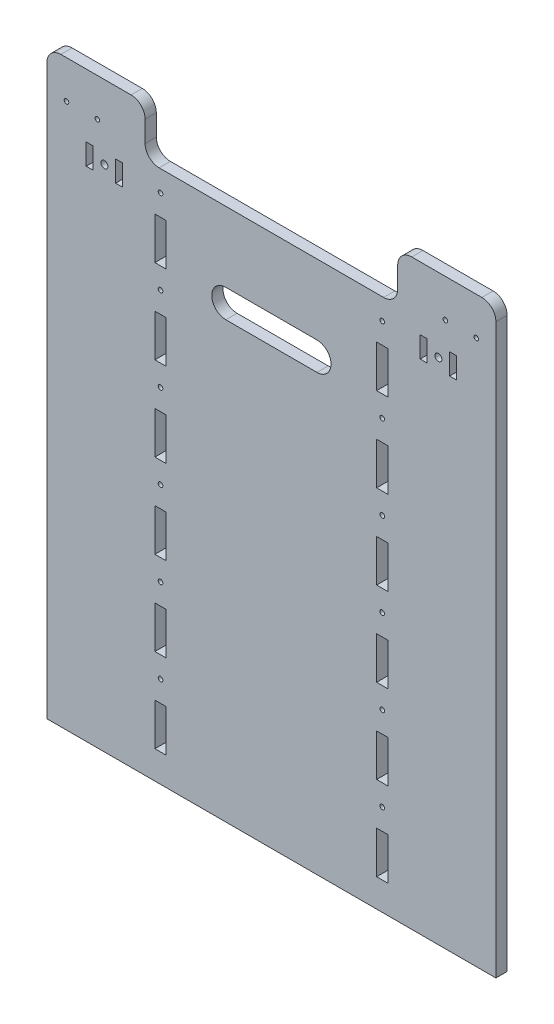
from build123d import *

# Parameters (mm, degrees)
SKETCH1_R           = 1.625
SKETCH1_R_2         = 2.5
SKETCH1_R_3         = 1.65
SKETCH1_W           = 8
SKETCH1_H           = 30
SKETCH1_W_2         = 5
SKETCH1_H_2         = 15
BOSS_EXTRUDE1_DEPTH = 8
FILLET1_R           = 10
CUT_EXTRUDE1_DEPTH  = 9


with BuildPart() as part:
    # Sketch1 → Boss-Extrude1 (new body)
    with BuildSketch(Plane.XY):
        Polygon((70, 380), (250, 380), (250, 415), (320, 415), (320, 0), (0, 0), (0, 415), (70, 415), align=None)
        with Locations((14, 388)):
            Circle(SKETCH1_R, mode=Mode.SUBTRACT)
        with Locations((36, 388)):
            Circle(SKETCH1_R, mode=Mode.SUBTRACT)
        with Locations((41, 362.5)):
            Circle(SKETCH1_R_2, mode=Mode.SUBTRACT)
        with Locations((279, 362.5)):
            Circle(SKETCH1_R_2, mode=Mode.SUBTRACT)
        with Locations((284, 388)):
            Circle(SKETCH1_R, mode=Mode.SUBTRACT)
        with Locations((306, 388)):
            Circle(SKETCH1_R, mode=Mode.SUBTRACT)
        with Locations((239, 365)):
            Circle(SKETCH1_R_3, mode=Mode.SUBTRACT)
        with Locations((81, 365)):
            Circle(SKETCH1_R_3, mode=Mode.SUBTRACT)
        with Locations((239, 305)):
            Circle(SKETCH1_R_3, mode=Mode.SUBTRACT)
        with Locations((81, 305)):
            Circle(SKETCH1_R_3, mode=Mode.SUBTRACT)
        with Locations((239, 245)):
            Circle(SKETCH1_R_3, mode=Mode.SUBTRACT)
        with Locations((81, 245)):
            Circle(SKETCH1_R_3, mode=Mode.SUBTRACT)
        with Locations((239, 185)):
            Circle(SKETCH1_R_3, mode=Mode.SUBTRACT)
        with Locations((81, 185)):
            Circle(SKETCH1_R_3, mode=Mode.SUBTRACT)
        with Locations((239, 125)):
            Circle(SKETCH1_R_3, mode=Mode.SUBTRACT)
        with Locations((81, 125)):
            Circle(SKETCH1_R_3, mode=Mode.SUBTRACT)
        with Locations((239, 65)):
            Circle(SKETCH1_R_3, mode=Mode.SUBTRACT)
        with Locations((81, 65)):
            Circle(SKETCH1_R_3, mode=Mode.SUBTRACT)
        with Locations((81, 35)):
            Rectangle(SKETCH1_W, SKETCH1_H, mode=Mode.SUBTRACT)
        with Locations((30.5, 362.5)):
            Rectangle(SKETCH1_W_2, SKETCH1_H_2, mode=Mode.SUBTRACT)
        with Locations((51.5, 362.5)):
            Rectangle(SKETCH1_W_2, SKETCH1_H_2, mode=Mode.SUBTRACT)
        with Locations((268.5, 362.5)):
            Rectangle(SKETCH1_W_2, SKETCH1_H_2, mode=Mode.SUBTRACT)
        with Locations((289.5, 362.5)):
            Rectangle(SKETCH1_W_2, SKETCH1_H_2, mode=Mode.SUBTRACT)
        with Locations((239, 35)):
            Rectangle(SKETCH1_W, SKETCH1_H, mode=Mode.SUBTRACT)
        with Locations((81, 95)):
            Rectangle(SKETCH1_W, SKETCH1_H, mode=Mode.SUBTRACT)
        with Locations((239, 95)):
            Rectangle(SKETCH1_W, SKETCH1_H, mode=Mode.SUBTRACT)
        with Locations((81, 155)):
            Rectangle(SKETCH1_W, SKETCH1_H, mode=Mode.SUBTRACT)
        with Locations((239, 155)):
            Rectangle(SKETCH1_W, SKETCH1_H, mode=Mode.SUBTRACT)
        with Locations((81, 215)):
            Rectangle(SKETCH1_W, SKETCH1_H, mode=Mode.SUBTRACT)
        with Locations((239, 215)):
            Rectangle(SKETCH1_W, SKETCH1_H, mode=Mode.SUBTRACT)
        with Locations((81, 275)):
            Rectangle(SKETCH1_W, SKETCH1_H, mode=Mode.SUBTRACT)
        with Locations((239, 275)):
            Rectangle(SKETCH1_W, SKETCH1_H, mode=Mode.SUBTRACT)
        with Locations((81, 335)):
            Rectangle(SKETCH1_W, SKETCH1_H, mode=Mode.SUBTRACT)
        with Locations((239, 335)):
            Rectangle(SKETCH1_W, SKETCH1_H, mode=Mode.SUBTRACT)
    extrude(amount=BOSS_EXTRUDE1_DEPTH)

    # Fillet1
    fillet1_edges = [part.edges().sort_by_distance(p)[0] for p in [
        (0, 415, 4),
        (70, 415, 4),
        (70, 380, 4),
        (250, 380, 4),
        (250, 415, 4),
        (320, 415, 4),
    ]]
    fillet(fillet1_edges, radius=FILLET1_R)

    # Sketch2 → Cut-Extrude1 (cut, through all)
    with BuildSketch(Plane.XY.offset(8)):
        with BuildLine():
            Line((127.5, 330), (192.5, 330))
            ThreePointArc((192.5, 330), (202.5, 320), (192.5, 310))
            Line((192.5, 310), (127.5, 310))
            ThreePointArc((127.5, 310), (117.5, 320), (127.5, 330))
        make_face()
    extrude(amount=-CUT_EXTRUDE1_DEPTH, mode=Mode.SUBTRACT)


solid = part.part
